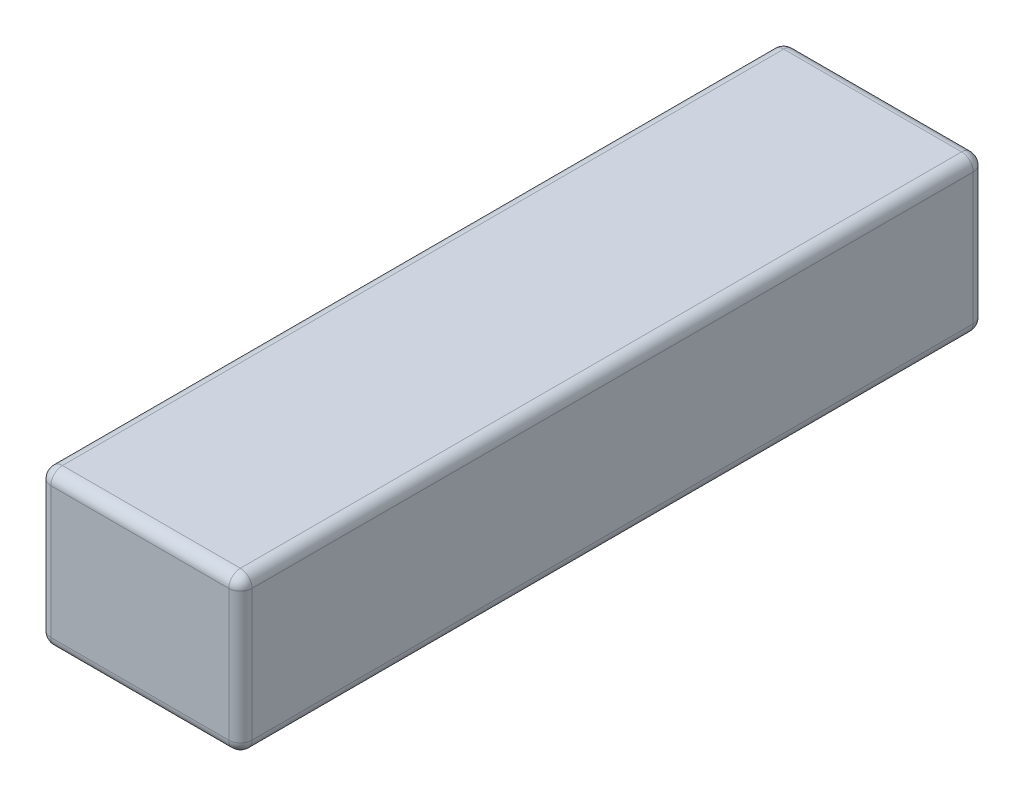
from build123d import *

# Parameters (mm, degrees)
SKIZZE1_W                       = 17.3
SKIZZE1_H                       = 13.3
AUFSATZ_LINEAR_AUSTRAGEN1_DEPTH = 64
VERRUNDUNG1_R                   = 1


with BuildPart() as part:
    # Skizze1 → Aufsatz-Linear austragen1 (new body)
    with BuildSketch(Plane.XY):
        Rectangle(SKIZZE1_W, SKIZZE1_H)
    extrude(amount=AUFSATZ_LINEAR_AUSTRAGEN1_DEPTH)

    # Verrundung1
    verrundung1_edges = [part.edges().sort_by_distance(p)[0] for p in [
        (8.65, 0, 64),
        (0, 6.65, 64),
        (-8.65, 0, 64),
        (0, 6.65, 0),
        (8.65, 0, 0),
        (0, -6.65, 0),
        (-8.65, 0, 0),
        (-8.65, 6.65, 32),
        (8.65, 6.65, 32),
        (8.65, -6.65, 32),
        (-8.65, -6.65, 32),
        (0, -6.65, 64),
    ]]
    fillet(verrundung1_edges, radius=VERRUNDUNG1_R)


solid = part.part
